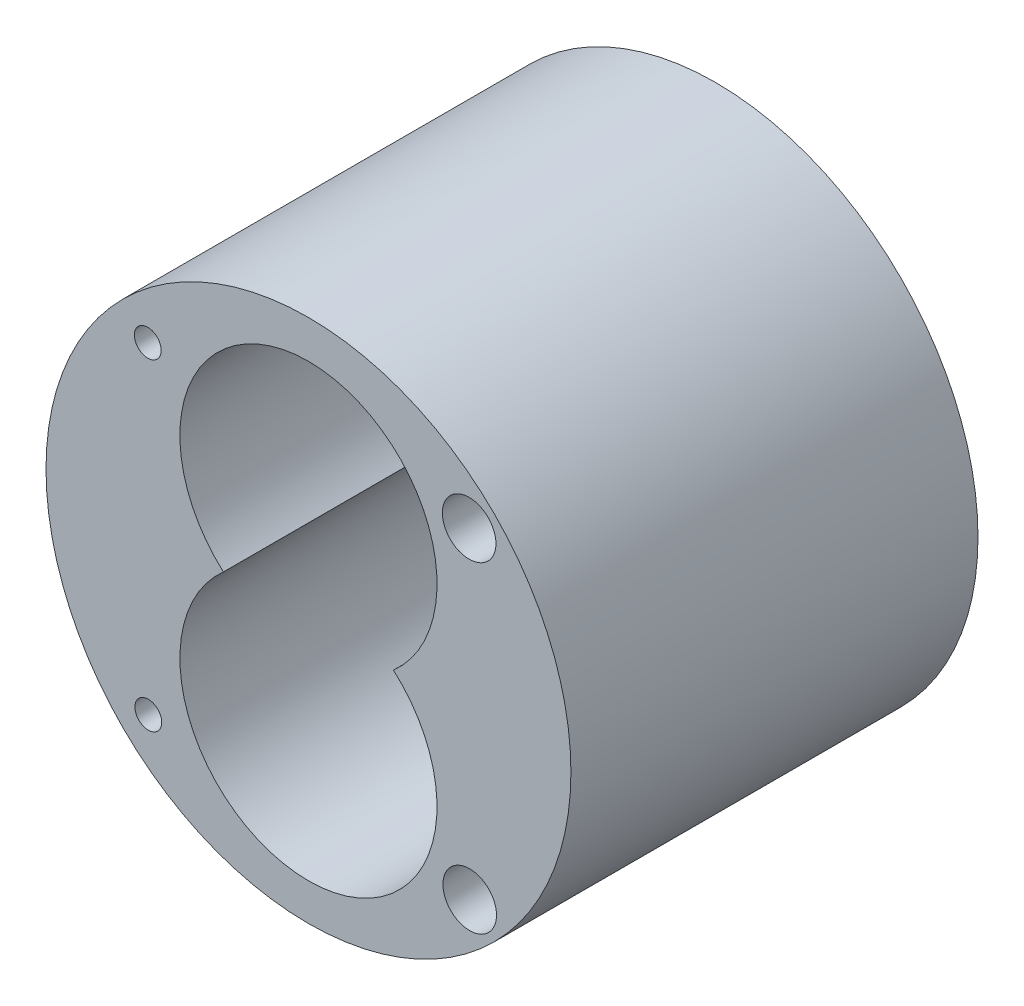
from build123d import *

# Parameters (mm, degrees)
SKETCH1_R           = 49
SKETCH1_R_2         = 2.5
SKETCH1_R_3         = 5
BOSS_EXTRUDE1_DEPTH = 76


with BuildPart() as part:
    # Sketch1 → Boss-Extrude1 (new body)
    with BuildSketch(Plane.XY):
        Circle(SKETCH1_R)
        with Locations((-30, 29.915097225)):
            Circle(SKETCH1_R_2, mode=Mode.SUBTRACT)
        with Locations((30, 29.915097225)):
            Circle(SKETCH1_R_3, mode=Mode.SUBTRACT)
        with Locations((-29.89855214, -30.18007542)):
            Circle(SKETCH1_R_2, mode=Mode.SUBTRACT)
        with Locations((30.10144786, -30.08971898)):
            Circle(SKETCH1_R_3, mode=Mode.SUBTRACT)
        with BuildLine():
            ThreePointArc((-15.874507866, -0.084902775), (0, -42.084902775), (15.874507866, -0.084902775))
            ThreePointArc((15.874507866, -0.084902775), (0, 41.915097225), (-15.874507866, -0.084902775))
        make_face(mode=Mode.SUBTRACT)
    extrude(amount=BOSS_EXTRUDE1_DEPTH)


solid = part.part
